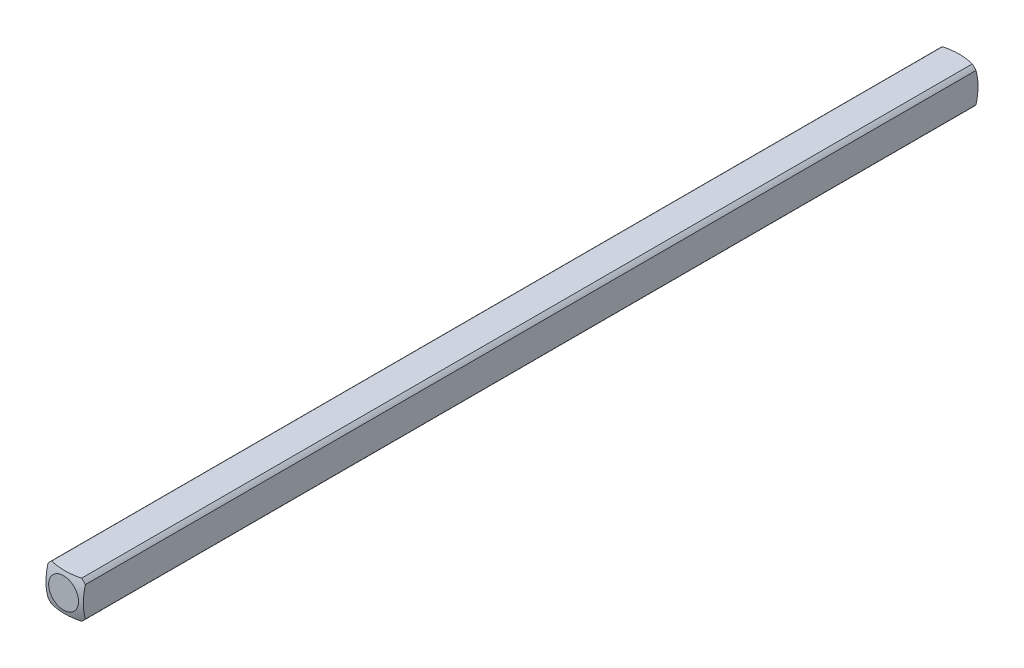
from build123d import *

# Parameters (mm, degrees)
SKETCH1_W           = 3.175
SKETCH1_H           = 3.175
BOSS_EXTRUDE1_DEPTH = 38.1
SKETCH2_OUTSIDE_W   = 12.848
SKETCH2_OUTSIDE_H   = 12.847
SKETCH2_OUTSIDE_R   = 2.032
CUT_EXTRUDE1_DEPTH  = 39.1


with BuildPart() as part:
    # Sketch1 → Boss-Extrude1 (new body)
    with BuildSketch(Plane.XY):
        Rectangle(SKETCH1_W, SKETCH1_H)
    extrude(amount=BOSS_EXTRUDE1_DEPTH)

    # Sketch2 outside → Cut-Extrude1 (cut, through all)
    with BuildSketch(Plane(origin=(0, 0, 0), x_dir=(-1, 0, 0), z_dir=(0, 0, -1))):
        with Locations((0, -0.0005)):
            Rectangle(SKETCH2_OUTSIDE_W, SKETCH2_OUTSIDE_H)
        Circle(SKETCH2_OUTSIDE_R, mode=Mode.SUBTRACT)
    extrude(amount=-CUT_EXTRUDE1_DEPTH, mode=Mode.SUBTRACT)

    # Sketch3 → Cut-Revolve1 (revolve, cut)
    with BuildSketch(Plane(origin=(0, 0, 0), x_dir=(1, 0, 0), z_dir=(0, 1, 0))):
        with BuildLine():
            Line((-5.053685963, -4.40273269), (-5.053685963, 5.740530545))
            Line((-5.053685963, 5.740530545), (0, 5.740530545))
            Line((0, 5.740530545), (0, 0.160877736))
            ThreePointArc((0, 0.160877736), (-3.404639553, -1.148866368), (-5.053685963, -4.40273269))
        make_face()
    revolve(axis=Axis((0, 0, 38.1), (0, 0, -1)), mode=Mode.SUBTRACT)

    # Mirror1: part across plane


with BuildPart() as part_1:
    add(part.part)
    add(part.part.mirror(Plane(origin=(0, 0, 38.1), x_dir=(1, 0, 0), z_dir=(0, 0, -1))))


solid = part_1.part
